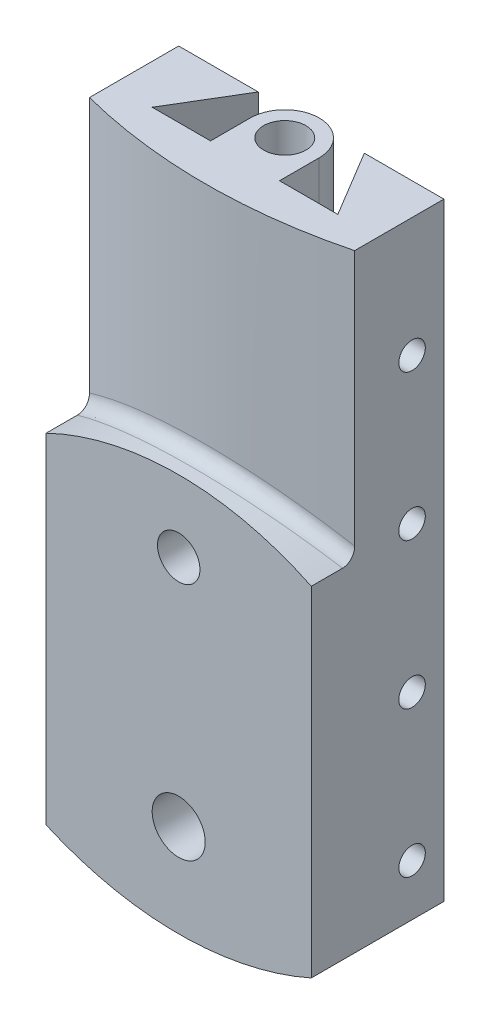
from build123d import *

# Parameters (mm, degrees)
SKETCH1_W               = 100
SKETCH1_H               = 240
SKETCH1_R               = 8
SKETCH1_R_2             = 10
BOSS_EXTRUDE1_DEPTH     = 25
SKETCH2_OUTSIDE_W       = 154.952
SKETCH2_OUTSIDE_H       = 294.952
SKETCH2_OUTSIDE_R       = 10
SKETCH2_OUTSIDE_R_2     = 8
CUT_EXTRUDE1_DEPTH      = 10
CUT_EXTRUDE2_START      = -50
SKETCH3_OUTSIDE_W       = 154.952
SKETCH3_OUTSIDE_H       = 294.952
CUT_EXTRUDE2_DEPTH      = 50
CUT_EXTRUDE7_REACH      = 242
SKETCH8_R               = 8
BOSS_EXTRUDE2_DEPTH     = 30
CUT_EXTRUDE8_REACH      = 242
CUT_EXTRUDE8_END_RADIUS = 115
CUT_EXTRUDE9_START      = -25.8
SKETCH10_R              = 5
CUT_EXTRUDE9_DEPTH      = 25.8
LPATTERN1_COUNT         = 4
LPATTERN1_PITCH         = 55
MIRROR1_START           = -25.8
MIRROR1_COPY_1_SKETCH_R = 5
MIRROR1_COPY_1_DEPTH    = 25.8
MIRROR1_COPY_2_SKETCH_R = 5
MIRROR1_COPY_2_DEPTH    = 25.8
MIRROR1_COPY_3_SKETCH_R = 5
MIRROR1_COPY_3_DEPTH    = 25.8
FILLET1_R               = 5


with BuildPart() as part:
    # Sketch1 → Boss-Extrude1 (new body, symmetric)
    with BuildSketch(Plane.XY):
        Rectangle(SKETCH1_W, SKETCH1_H)
        with Locations((0, 3)):
            Circle(SKETCH1_R, mode=Mode.SUBTRACT)
        with Locations((0, -85)):
            Circle(SKETCH1_R_2, mode=Mode.SUBTRACT)
    extrude(amount=BOSS_EXTRUDE1_DEPTH, both=True)

    # Sketch2 outside → Cut-Extrude1 (cut)
    with BuildSketch(Plane.XY.offset(25)):
        Rectangle(SKETCH2_OUTSIDE_W, SKETCH2_OUTSIDE_H)
        with BuildLine():
            Line((50, -120), (50, 18.561575886))
            ThreePointArc((50, 18.561575886), (0, 30), (-50, 18.561575886))
            Line((-50, 18.561575886), (-50, -120))
            Line((-50, -120), (50, -120))
        make_face(mode=Mode.SUBTRACT)
        with Locations((0, -85)):
            Circle(SKETCH2_OUTSIDE_R)
        with Locations((0, 3)):
            Circle(SKETCH2_OUTSIDE_R_2)
    extrude(amount=-CUT_EXTRUDE1_DEPTH, mode=Mode.SUBTRACT)

    # Sketch3 outside → Cut-Extrude2 (cut)
    with BuildSketch(Plane.XY.offset(25).offset(CUT_EXTRUDE2_START)):
        Rectangle(SKETCH3_OUTSIDE_W, SKETCH3_OUTSIDE_H)
        with BuildLine():
            Line((50, 120), (-50, 120))
            Line((-50, 120), (-50, -109.378823628))
            ThreePointArc((-50, -109.378823628), (0, -120), (50, -109.378823628))
            Line((50, -109.378823628), (50, 120))
        make_face(mode=Mode.SUBTRACT)
    extrude(amount=CUT_EXTRUDE2_DEPTH, mode=Mode.SUBTRACT)

    # Sketch7 → Cut-Extrude7 (cut, up to next)
    with BuildSketch(Plane(origin=(0, 120, 0), x_dir=(1, 0, 0), z_dir=(0, 1, 0)), mode=Mode.PRIVATE) as cut_extrude7_sk1:
        Polygon((-35, 0), (35, 0), (20, 25), (-20, 25), align=None)
    cut_extrude7_tool1 = extrude(cut_extrude7_sk1.sketch, amount=-CUT_EXTRUDE7_REACH, mode=Mode.PRIVATE) & part.part
    add(cut_extrude7_tool1.solids().sort_by_distance((0, 120, -11.363636))[0], mode=Mode.SUBTRACT)

    # Sketch8 → Boss-Extrude2 (add)
    with BuildSketch(Plane(origin=(0, 120, 0), x_dir=(1, 0, 0), z_dir=(0, 1, 0))):
        with BuildLine():
            Line((13, 15), (13, 0))
            Line((13, 0), (-13, 0))
            Line((-13, 0), (-13, 15))
            ThreePointArc((-13, 15), (0, 28), (13, 15))
        make_face()
        with Locations(Location((0, 15, 0), (0, 0, 270))):  # turned: the seam where the file's is
            Circle(SKETCH8_R, mode=Mode.SUBTRACT)
    extrude(amount=-BOSS_EXTRUDE2_DEPTH)

    # Cut-Extrude8: up to this cylinder (the profile starts outside it)
    cut_extrude8_end = Plane(origin=(0, -85, 18.800927), z_dir=(0, 0, 1)) * Cylinder(CUT_EXTRUDE8_END_RADIUS, 715, mode=Mode.PRIVATE)
    # Sketch9 → Cut-Extrude8 (cut, up to the surface)
    with BuildSketch(Plane(origin=(0, 120, 0), x_dir=(1, 0, 0), z_dir=(0, 1, 0)), mode=Mode.PRIVATE) as cut_extrude8_sk1:
        with BuildLine():
            Line((50, -8.64916731), (50, -25))
            Line((50, -25), (-50, -25))
            Line((-50, -25), (-50, -8.64916731))
            ThreePointArc((-50, -8.64916731), (0, -15), (50, -8.64916731))
        make_face()
    cut_extrude8_tool1 = extrude(cut_extrude8_sk1.sketch, amount=-CUT_EXTRUDE8_REACH, mode=Mode.PRIVATE) - cut_extrude8_end
    add(cut_extrude8_tool1.solids().sort_by_distance((0, 120, 18.800927))[0], mode=Mode.SUBTRACT)

    # Sketch10 → Cut-Extrude9 (cut)
    with BuildSketch(Plane(origin=(50, 0, 0), x_dir=(0, 0, -1), z_dir=(1, 0, 0)).offset(CUT_EXTRUDE9_START)):
        with Locations((13, -90)):
            Circle(SKETCH10_R)
    cut_extrude9 = extrude(amount=CUT_EXTRUDE9_DEPTH, mode=Mode.SUBTRACT)

    # LPattern1: Cut-Extrude9 ×4
    with Locations(*[(0, i * LPATTERN1_PITCH, 0) for i in range(1, LPATTERN1_COUNT)]):
        add(cut_extrude9, mode=Mode.SUBTRACT)

    # Mirror1: Cut-Extrude9 across plane
    add(cut_extrude9.mirror(Plane(origin=(0, 0, 0), x_dir=(0, 0, 1), z_dir=(1, 0, 0))), mode=Mode.SUBTRACT)

    # Mirror1 copy 1 sketch → Mirror1 copy 1 (cut)
    with BuildSketch(Plane(origin=(-50, 55, 0), x_dir=(0, 0, -1), z_dir=(-1, 0, 0)).offset(MIRROR1_START)):
        with Locations((13, 90)):
            Circle(MIRROR1_COPY_1_SKETCH_R)
    extrude(amount=MIRROR1_COPY_1_DEPTH, mode=Mode.SUBTRACT)

    # Mirror1 copy 2 sketch → Mirror1 copy 2 (cut)
    with BuildSketch(Plane(origin=(-50, 110, 0), x_dir=(0, 0, -1), z_dir=(-1, 0, 0)).offset(MIRROR1_START)):
        with Locations((13, 90)):
            Circle(MIRROR1_COPY_2_SKETCH_R)
    extrude(amount=MIRROR1_COPY_2_DEPTH, mode=Mode.SUBTRACT)

    # Mirror1 copy 3 sketch → Mirror1 copy 3 (cut)
    with BuildSketch(Plane(origin=(-50, 165, 0), x_dir=(0, 0, -1), z_dir=(-1, 0, 0)).offset(MIRROR1_START)):
        with Locations((13, 90)):
            Circle(MIRROR1_COPY_3_SKETCH_R)
    extrude(amount=MIRROR1_COPY_3_DEPTH, mode=Mode.SUBTRACT)

    # Fillet1
    fillet1_edges = [part.edges().sort_by_distance(p)[0] for p in [
        (-1e-09, 30, 15),
    ]]
    fillet(fillet1_edges, radius=FILLET1_R)


solid = part.part
